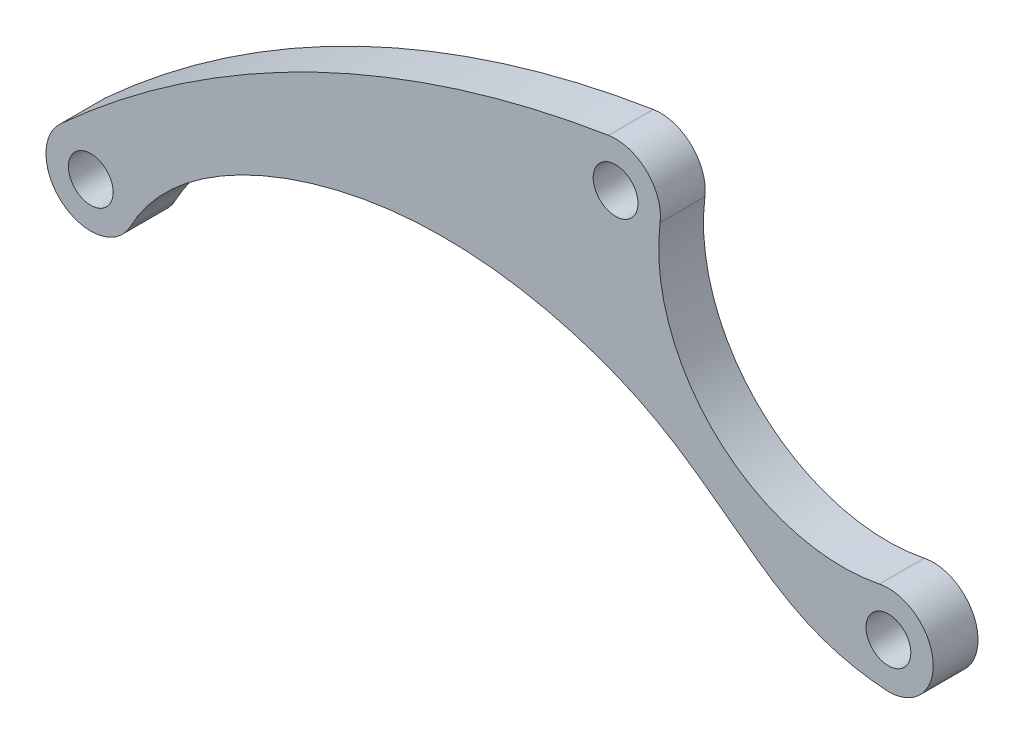
from build123d import *

# Parameters (mm, degrees)
SKETCH_1_R          = 2.5
EXTRUDE_1_DEPTH     = 2.5
SKETCH_2_OUTSIDE_W  = 122.246
SKETCH_2_OUTSIDE_H  = 61.454
CUT_EXTRUDE_1_DEPTH = 5


with BuildPart() as part:
    # 草圖1 → 填料-伸長1 (new body, symmetric)
    with BuildSketch(Plane.XY):
        with BuildLine():
            Line((0, -5), (89, -5))
            ThreePointArc((89, -5), (93.65494965, -1.825224302), (92.398530891, 3.667422499))
            Line((92.398530891, 3.667422499), (61.958924149, 31.87522889))
            ThreePointArc((61.958924149, 31.87522889), (60.254323258, 32.912123681), (58.279993488, 33.199937797))
            ThreePointArc((58.279993488, 33.199937797), (24.304322989, 24.433991013), (-3.728789315, 3.331085445))
            ThreePointArc((-3.728789315, 3.331085445), (-4.563738995, -2.042617533), (0, -5))
        make_face()
        with Locations((89, 0)):
            Circle(SKETCH_1_R, mode=Mode.SUBTRACT)
        with Locations((58.560393258, 28.207806391)):
            Circle(SKETCH_1_R, mode=Mode.SUBTRACT)
        Circle(SKETCH_1_R, mode=Mode.SUBTRACT)
    extrude(amount=EXTRUDE_1_DEPTH, both=True)

    # 草圖2 outside → 除料-伸長1 (cut)
    with BuildSketch(Plane.XY.offset(2.5)):
        with Locations((44.5, 14.104)):
            Rectangle(SKETCH_2_OUTSIDE_W, SKETCH_2_OUTSIDE_H)
        with BuildLine():
            ThreePointArc((89, -5), (93.974802144, 0.501341826), (88.002369443, 4.899462549))
            ThreePointArc((88.002369443, 4.899462549), (69.941203596, 9.961169209), (63.521504981, 27.585415456))
            ThreePointArc((63.521504981, 27.585415456), (62.036094915, 31.802176711), (57.771858796, 33.145236229))
            ThreePointArc((57.771858796, 33.145236229), (25.047082101, 22.891997102), (-3.369271636, 3.694321134))
            ThreePointArc((-3.369271636, 3.694321134), (-3.0561059, -3.957299171), (4.426117807, -2.325829134))
            add(Edge.make_bspline(
                [(4.426117807, -2.325829134), (8.332752679, 5.108606147), (26.800732902, 15.21507614), (48.740337839, 14.473140614), (64.347418315, 8.195396514), (74.817720457, -0.231553234), (81.784825156, -4.537988126), (89, -5)],
                knots=[0, 0, 0, 0, 0.281768749, 0.583331101, 0.690814507, 0.820319315, 1, 1, 1, 1], degree=3))
        make_face(mode=Mode.SUBTRACT)
    extrude(amount=-CUT_EXTRUDE_1_DEPTH, mode=Mode.SUBTRACT)


solid = part.part
